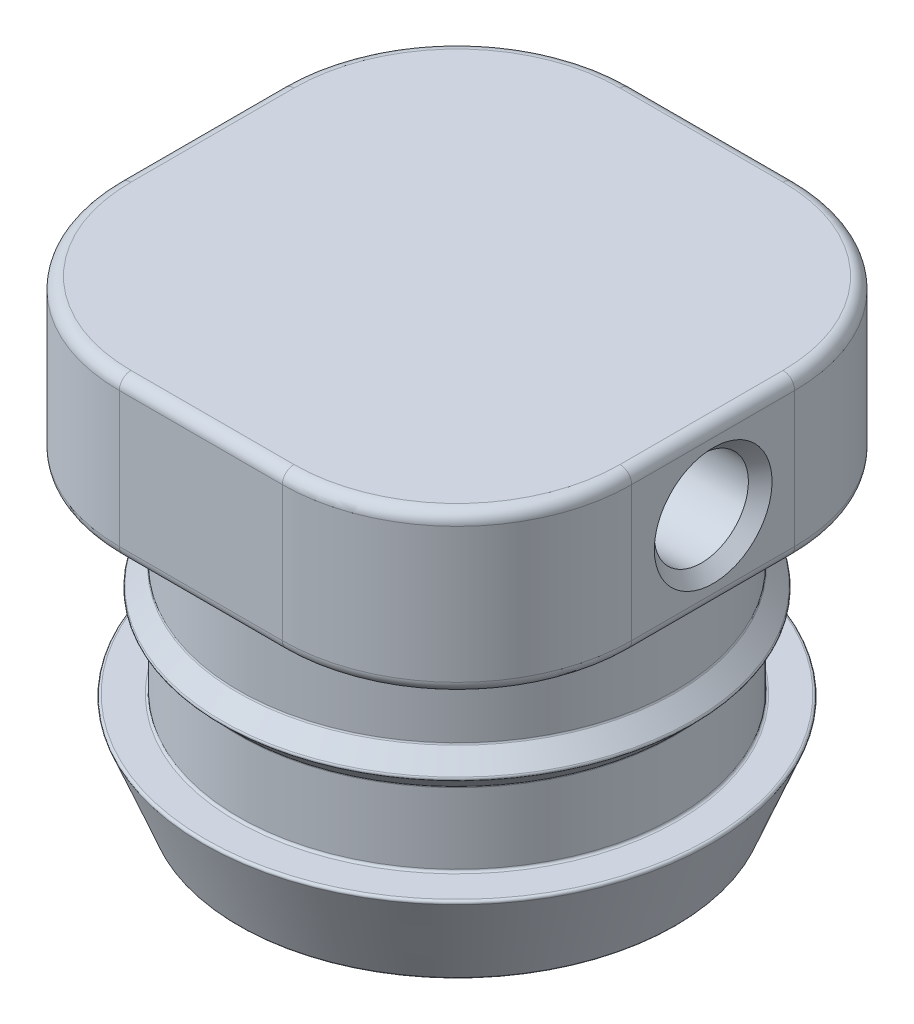
from build123d import *

# Parameters (mm, degrees)
BOSS_EXTRUDE1_DEPTH         = 11
SKETCH3_R                   = 4
CUT_EXTRUDE1_DEPTH          = 18.5
F_10_32_TAPPED_HOLE1_REACH  = 33.389
F_10_32_TAPPED_HOLE1_BORE_R = 2.0193
FILLET3_R                   = 0.1
CHAMFER1_SIZE               = 0.508
FILLET6_R                   = 7.5
FILLET8_R                   = 0.5


with BuildPart() as part:
    # Sketch1 → Boss-Extrude1 (new, symmetric)
    with BuildSketch(Plane.XY):
        Polygon((-11, 0), (0, 0), (11, 0), (11, -6.8), (-11, -6.8), align=None)
    extrude(amount=BOSS_EXTRUDE1_DEPTH, both=True)

    # Sketch2 → Revolve1 (revolve)
    with BuildSketch(Plane.XY, mode=Mode.PRIVATE) as revolve1_sk:
        Polygon((0, -6.8), (9.365, -6.8), (9.365, -10.76875), (10.15875, -11.5625), (9.365, -12.35625), (9.365, -15.53125), (10.9525, -15.53125), (9.365, -19.5), (0, -19.5), align=None)
    revolve(revolve1_sk.sketch.rotate(Axis((0, 9.54404991, 0), (0, -1, 0)), 180), axis=Axis((0, 9.54404991, 0), (0, -1, 0)))

    # Sketch3 → Cut-Extrude1 (cut)
    with BuildSketch(Plane.XZ.offset(19.5)):
        Circle(SKETCH3_R)
    extrude(amount=-CUT_EXTRUDE1_DEPTH, mode=Mode.SUBTRACT)

    # #10-32 Tapped Hole1 bore → #10-32 Tapped Hole1 (cut, up to next)
    with BuildSketch(Plane(origin=(11, 0, 0), x_dir=(0, 0, -1), z_dir=(1, 0, 0)), mode=Mode.PRIVATE) as f_10_32_tapped_hole1_sk1:
        with Locations((0, -3.4)):
            Circle(F_10_32_TAPPED_HOLE1_BORE_R)
    f_10_32_tapped_hole1_tool1 = extrude(f_10_32_tapped_hole1_sk1.sketch, amount=-F_10_32_TAPPED_HOLE1_REACH, mode=Mode.PRIVATE) & part.part
    add(f_10_32_tapped_hole1_tool1.solids().sort_by_distance((11, -3.4, 0))[0], mode=Mode.SUBTRACT)

    # Fillet3
    fillet3_edges = [part.edges().sort_by_distance(p)[0] for p in [
        (9.365, -6.8, 0),
        (9.365, -10.76875, 0),
        (10.15875, -11.5625, 0),
        (9.365, -12.35625, 0),
        (9.365, -15.53125, 0),
        (10.9525, -15.53125, 0),
        (9.365, -19.5, 0),
        (-4, -1, 0),
    ]]
    fillet(fillet3_edges, radius=FILLET3_R)

    # Chamfer1
    chamfer1_edges = [part.edges().sort_by_distance(p)[0] for p in [
        (11, -3.4, 2.0193),
    ]]
    chamfer(chamfer1_edges, length=CHAMFER1_SIZE)

    # Fillet6
    fillet6_edges = [part.edges().sort_by_distance(p)[0] for p in [
        (-11, -3.4, 11),
        (11, -3.4, 11),
        (11, -3.4, -11),
        (-11, -3.4, -11),
    ]]
    fillet(fillet6_edges, radius=FILLET6_R)

    # Fillet8
    fillet8_edges = [part.edges().sort_by_distance(p)[0] for p in [
        (-4, -19.5, 0),
        (3.736008632, -4.826650978, -1.429069455),
        (11, 0, 0),
        (11, -6.8, 0),
        (0, 0, -11),
        (-11, 0, 0),
        (0, 0, 11),
        (8.803300859, 0, 8.803300859),
        (-8.803300859, 0, 8.803300859),
        (-8.803300859, 0, -8.803300859),
        (8.803300859, 0, -8.803300859),
        (0, -6.8, -11),
        (0, -6.8, 11),
        (-11, -6.8, 0),
        (8.803300859, -6.8, 8.803300859),
        (-8.803300859, -6.8, 8.803300859),
        (-8.803300859, -6.8, -8.803300859),
        (8.803300859, -6.8, -8.803300859),
    ]]
    fillet(fillet8_edges, radius=FILLET8_R)


solid = part.part
